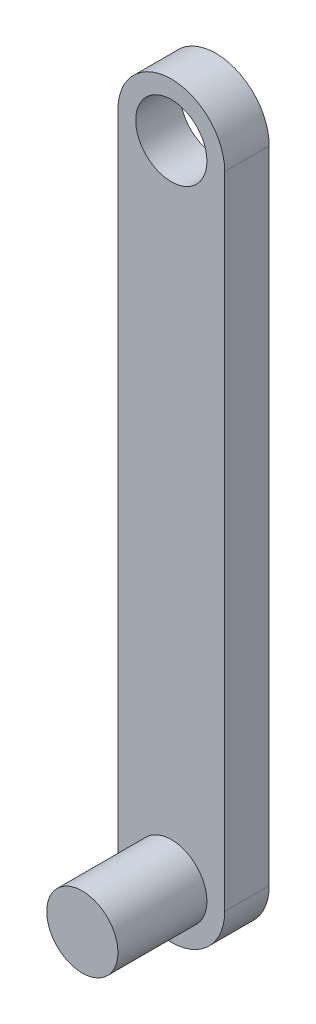
from build123d import *

# Parameters (mm, degrees)
SKETCH1_R           = 4
BOSS_EXTRUDE1_DEPTH = 5
SKETCH2_R           = 4
BOSS_EXTRUDE2_DEPTH = 10


with BuildPart() as part:
    # Sketch1 → Boss-Extrude1 (new body)
    with BuildSketch(Plane.XY):
        with BuildLine():
            Line((-6, -36), (-6, 36))
            ThreePointArc((-6, 36), (0, 42), (6, 36))
            Line((6, 36), (6, -36))
            ThreePointArc((6, -36), (0, -42), (-6, -36))
        make_face()
        with Locations((0, 36)):
            Circle(SKETCH1_R, mode=Mode.SUBTRACT)
    extrude(amount=BOSS_EXTRUDE1_DEPTH)

    # Sketch2 → Boss-Extrude2 (add)
    with BuildSketch(Plane.XY.offset(5)):
        with Locations((0, -36)):
            Circle(SKETCH2_R)
    extrude(amount=BOSS_EXTRUDE2_DEPTH)


solid = part.part
